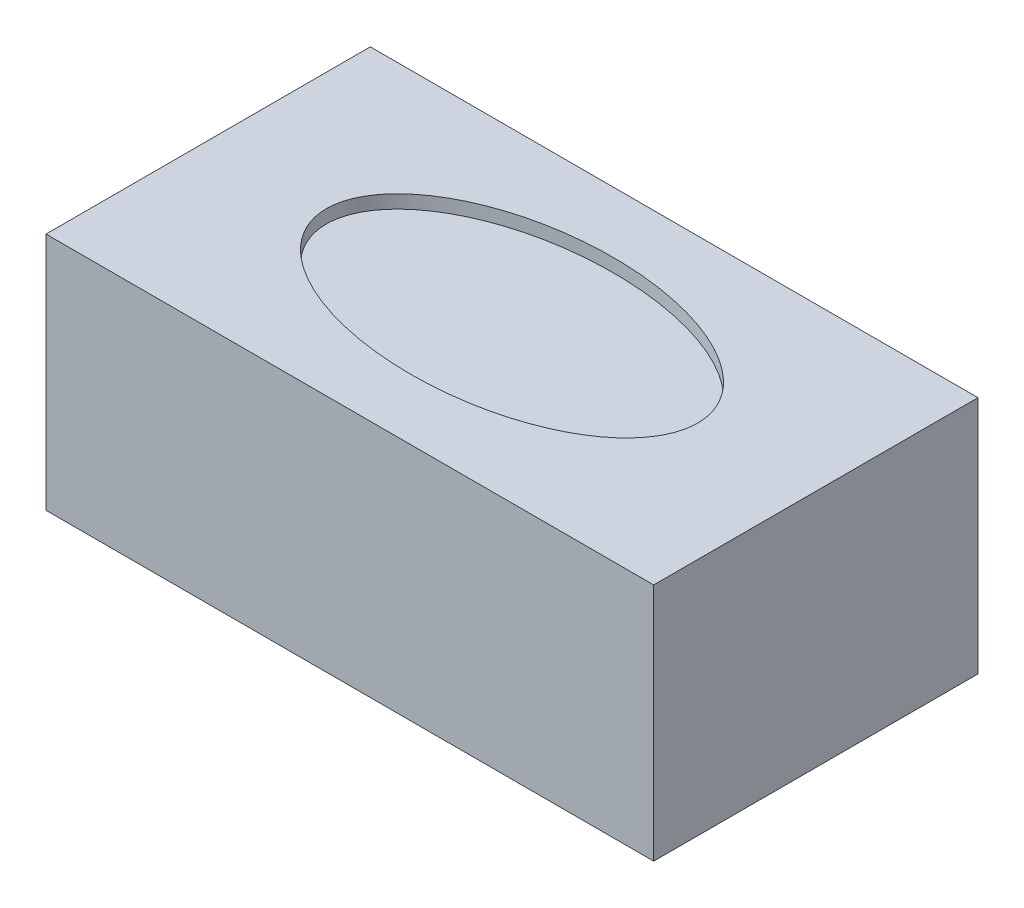
from build123d import *

# Parameters (mm, degrees)
SKETCH1_W           = 228.6
SKETCH1_H           = 122
BOSS_EXTRUDE1_DEPTH = 90
SKETCH2_RX          = 69.85
SKETCH2_RY          = 38.1
CUT_EXTRUDE1_DEPTH  = 5


with BuildPart() as part:
    # Sketch1 → Boss-Extrude1 (new body)
    with BuildSketch(Plane(origin=(0, 0, 0), x_dir=(1, 0, 0), z_dir=(0, 1, 0))):
        Rectangle(SKETCH1_W, SKETCH1_H)
    extrude(amount=BOSS_EXTRUDE1_DEPTH)

    # Sketch2 → Cut-Extrude1 (cut)
    with BuildSketch(Plane(origin=(0, 90, 0), x_dir=(1, 0, 0), z_dir=(0, 1, 0))):
        with Locations(Location((0, 0), (0, 0, 180))):
            Ellipse(SKETCH2_RX, SKETCH2_RY)
    extrude(amount=-CUT_EXTRUDE1_DEPTH, mode=Mode.SUBTRACT)


solid = part.part
